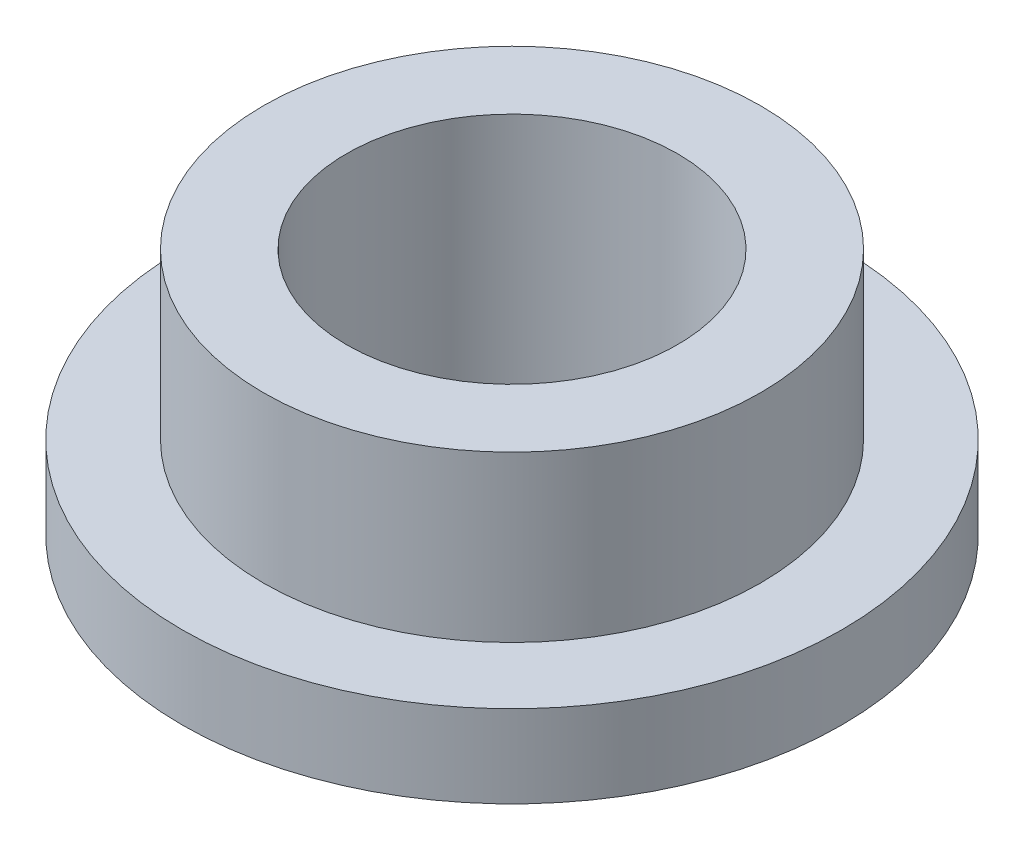
from build123d import *

# Parameters (mm, degrees)
SKETCH2_R           = 4.7879
SKETCH2_R_2         = 3.1877
BOSS_EXTRUDE1_DEPTH = 4.7625
SKETCH3_R           = 6.35
SKETCH3_R_2         = 4.7879
BOSS_EXTRUDE2_DEPTH = 1.5875


with BuildPart() as part:
    # Sketch2 → Boss-Extrude1 (new body)
    with BuildSketch(Plane(origin=(0, 0, 0), x_dir=(1, 0, 0), z_dir=(0, 1, 0))):
        Circle(SKETCH2_R)
        Circle(SKETCH2_R_2, mode=Mode.SUBTRACT)
    extrude(amount=BOSS_EXTRUDE1_DEPTH)

    # Sketch3 → Boss-Extrude2 (add)
    with BuildSketch(Plane(origin=(0, 0, 0), x_dir=(1, 0, 0), z_dir=(0, 1, 0))):
        Circle(SKETCH3_R)
        Circle(SKETCH3_R_2, mode=Mode.SUBTRACT)
    extrude(amount=BOSS_EXTRUDE2_DEPTH)


solid = part.part
